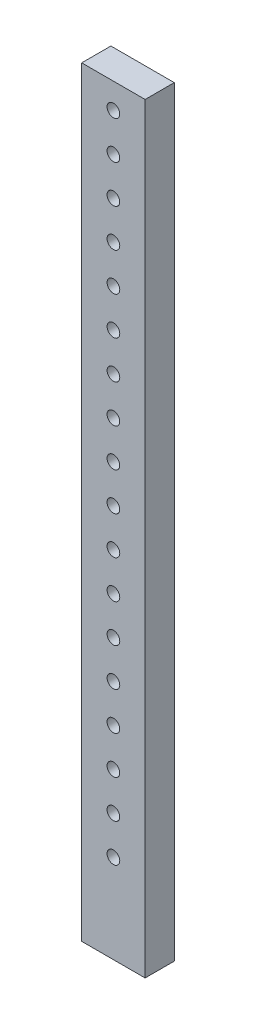
from build123d import *

# Parameters (mm, degrees)
SKETCH2_W           = 50
SKETCH2_H           = 600
SKETCH2_R           = 5
BOSS_EXTRUDE1_DEPTH = 23


with BuildPart() as part:
    # Sketch2 → Boss-Extrude1 (new body)
    with BuildSketch(Plane.XY):
        Rectangle(SKETCH2_W, SKETCH2_H)
        with Locations((0, 280)):
            Circle(SKETCH2_R, mode=Mode.SUBTRACT)
        with Locations((0, 250)):
            Circle(SKETCH2_R, mode=Mode.SUBTRACT)
        with Locations((0, 220)):
            Circle(SKETCH2_R, mode=Mode.SUBTRACT)
        with Locations((0, 190)):
            Circle(SKETCH2_R, mode=Mode.SUBTRACT)
        with Locations((0, 160)):
            Circle(SKETCH2_R, mode=Mode.SUBTRACT)
        with Locations((0, 130)):
            Circle(SKETCH2_R, mode=Mode.SUBTRACT)
        with Locations((0, 100)):
            Circle(SKETCH2_R, mode=Mode.SUBTRACT)
        with Locations((0, 70)):
            Circle(SKETCH2_R, mode=Mode.SUBTRACT)
        with Locations((0, 40)):
            Circle(SKETCH2_R, mode=Mode.SUBTRACT)
        with Locations((0, 10)):
            Circle(SKETCH2_R, mode=Mode.SUBTRACT)
        with Locations((0, -20)):
            Circle(SKETCH2_R, mode=Mode.SUBTRACT)
        with Locations((0, -50)):
            Circle(SKETCH2_R, mode=Mode.SUBTRACT)
        with Locations((0, -80)):
            Circle(SKETCH2_R, mode=Mode.SUBTRACT)
        with Locations((0, -110)):
            Circle(SKETCH2_R, mode=Mode.SUBTRACT)
        with Locations((0, -140)):
            Circle(SKETCH2_R, mode=Mode.SUBTRACT)
        with Locations((0, -170)):
            Circle(SKETCH2_R, mode=Mode.SUBTRACT)
        with Locations((0, -200)):
            Circle(SKETCH2_R, mode=Mode.SUBTRACT)
        with Locations((0, -230)):
            Circle(SKETCH2_R, mode=Mode.SUBTRACT)
    extrude(amount=BOSS_EXTRUDE1_DEPTH)


solid = part.part
